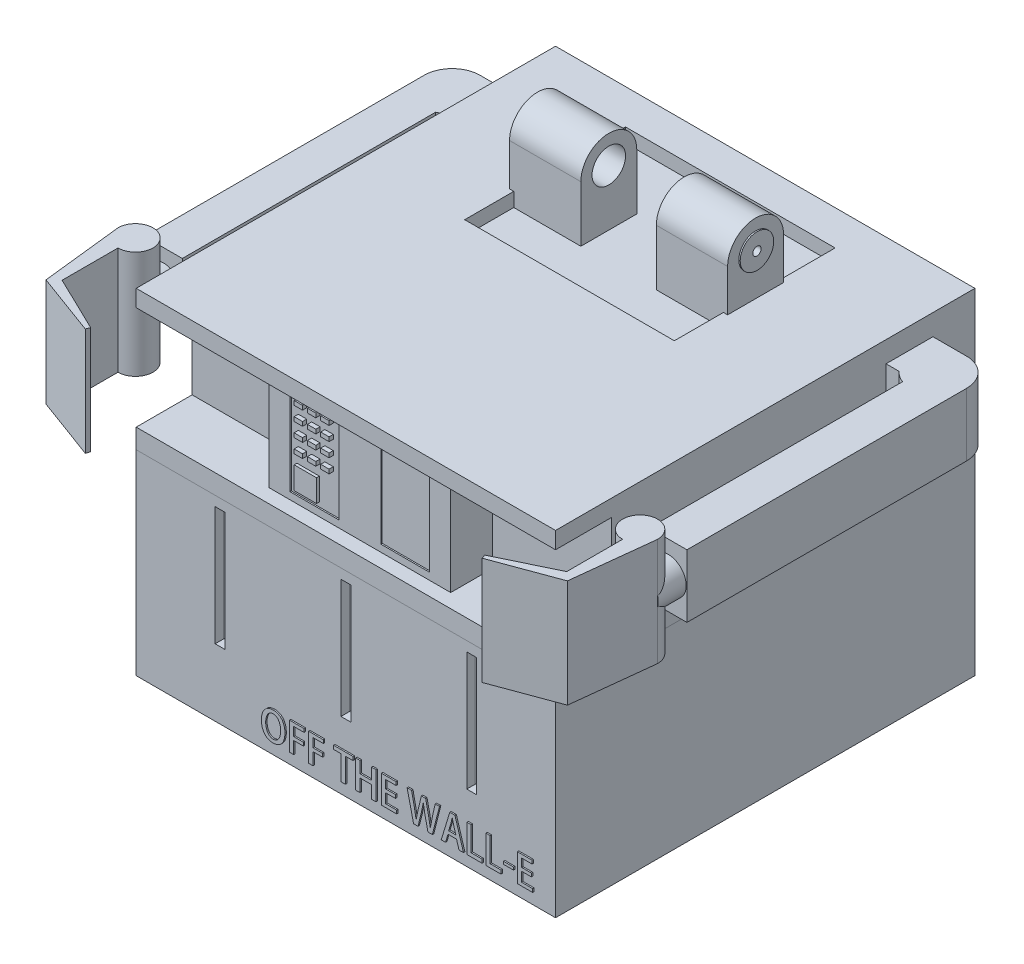
from build123d import *

# Parameters (mm, degrees)
BASE_W                                = 15
BASE_H                                = 15
BOTTOM_BASE_DEPTH                     = 7
BASE2_W                               = 15
BASE2_H                               = 15
TOP_BASE_DEPTH                        = 5
SKETCH3_W                             = 15
SKETCH3_H                             = 3.7
TOP_CUT_DEPTH                         = 2
SKETCH4_W                             = 6.5
SKETCH4_H                             = 3.7
BIG_BUTTON_PLATE_DEPTH                = 1.5
SKETCH6_W                             = 0.3
SKETCH6_H                             = 0.15
F_3X4_BUTTONS_DEPTH                   = 0.1
SKETCH9_W                             = 0.8
SKETCH9_H                             = 0.8
BIG_SQUARE_BUTTON_DEPTH               = 0.1
SKETCH6_6_W                           = 1.75
SKETCH6_6_H                           = 3.2
SKETCH6_6_W_2                         = 0.3
SKETCH6_6_H_2                         = 0.15
PHONE_DEPTH                           = 0.05
SKETCH14_W                            = 0.35
SKETCH14_H                            = 4.25
F_3_BOTTOM_SLOTS_DEPTH                = 0.35
FILLET1_R                             = 0.05
SKETCH15_W                            = 7.5
SKETCH15_H                            = 5.75
TOP_EXTRUDE_CUT_DEPTH                 = 0.5
RIGHT_HEAD_HOLDER_1_DEPTH             = 2.4
RIGHT_HEAD_HOLDER_1_DEPTH_BACK        = 0.15
SKETCH19_R                            = 0.6
RIGHT_HEAD_HOLDER_2_DEPTH             = 0.35
RIGHT_HEAD_HOLDER_2_DEPTH_BACK        = 0.2
SKETCH19_3_R                          = 0.6
SKETCH19_3_R_2                        = 0.15
LEFT_HEAD_HOLDER_1_DEPTH              = 2.4
LEFT_HEAD_HOLDER_1_DEPTH_BACK         = 0.15
SKETCH18_R                            = 0.6
LEFT_HEAD_HOLDER_2_DEPTH              = 0.35
LEFT_HEAD_HOLDER_2_DEPTH_BACK         = 0.2
SKETCH18_3_R                          = 0.6
SKETCH18_3_R_2                        = 0.15
ARMS_DEPTH                            = 2.25
CLAWS_DEPTH                           = 0.8
CLAWS_DEPTH_BACK                      = 3.05
CLAWS_2_DEPTH                         = 0.8
CLAWS_2_DEPTH_BACK                    = 3.05
SKETCH26_R                            = 0.65
CIRCLE_TO_ATTACH_ARMS_AND_CLAWS_DEPTH = 1
SKETCH28_W                            = 0.359189424
SKETCH28_H                            = 0.095238297
BOSS_EXTRUDE26_DEPTH                  = 0.05
SKETCH33_W                            = 1.5
SKETCH33_H                            = 1.5
CUT_EXTRUDE1_DEPTH                    = 2.5


with BuildPart() as part:
    # Base → Bottom base (new body)
    with BuildSketch(Plane(origin=(0, 0, 0), x_dir=(1, 0, 0), z_dir=(0, 1, 0))):
        Rectangle(BASE_W, BASE_H)
    extrude(amount=BOTTOM_BASE_DEPTH)

    # Sketch14 → 3 bottom slots (cut)
    with BuildSketch(Plane.XY.offset(7.5)):
        with Locations((0, 4.525)):
            Rectangle(SKETCH14_W, SKETCH14_H)
        with Locations((4.5, 4.525)):
            Rectangle(SKETCH14_W, SKETCH14_H)
        with Locations((-4.5, 4.525)):
            Rectangle(SKETCH14_W, SKETCH14_H)
    extrude(amount=-F_3_BOTTOM_SLOTS_DEPTH, mode=Mode.SUBTRACT)

    # Fillet1
    fillet1_edges = [part.edges().sort_by_distance(p)[0] for p in [
        (-0.175, 4.525, 7.15),
        (-4.675, 4.525, 7.15),
        (4.675, 4.525, 7.15),
        (4.5, 6.65, 7.15),
        (0.175, 4.525, 7.15),
        (0, 6.65, 7.15),
        (4.325, 4.525, 7.15),
        (4.5, 2.4, 7.15),
        (0, 2.4, 7.15),
        (-4.5, 2.4, 7.15),
        (-4.5, 6.65, 7.15),
        (-4.325, 4.525, 7.15),
    ]]
    fillet(fillet1_edges, radius=FILLET1_R)

    # Sketch28 → Boss-Extrude26 (add)
    # profile 1 of 12: a face of its own
    with BuildSketch(Plane.XY.offset(7.5)):
        with BuildLine():
            add(Edge.make_bspline(
                [(-2.542773415, 1.438775136), (-2.55882584, 1.438110923), (-2.59017136, 1.436813916), (-2.635834672, 1.429654226), (-2.678976734, 1.41865114), (-2.719463386, 1.403035452), (-2.757423202, 1.38326681), (-2.792716073, 1.359116703), (-2.825399223, 1.330752787), (-2.855279169, 1.298345473), (-2.882055278, 1.262197262), (-2.905669966, 1.222690536), (-2.925377124, 1.17977718), (-2.941932195, 1.133846801), (-2.954655386, 1.08466898), (-2.964079137, 1.032377645), (-2.969951963, 0.976854424), (-2.97105014, 0.938758011), (-2.971613422, 0.919217401)],
                knots=[0, 0, 0, 0, 1.01693825, 1.985772131, 2.921518734, 3.832117633, 4.727948323, 5.626511184, 6.534414133, 7.463288783, 8.412839634, 9.378967074, 10.373196777, 11.399194858, 12.46754142, 13.586614818, 14.762113956, 16, 16, 16, 16], degree=3))
            add(Edge.make_bspline(
                [(-2.971613422, 0.919217401), (-2.971208289, 0.900429172), (-2.970416523, 0.863710668), (-2.964426968, 0.810220053), (-2.956119813, 0.759588063), (-2.943575482, 0.712087769), (-2.928381776, 0.667333139), (-2.909052276, 0.625858504), (-2.886964026, 0.587076746), (-2.8612577, 0.55170149), (-2.832800775, 0.519545639), (-2.801228268, 0.491619405), (-2.766992422, 0.46781399), (-2.730017847, 0.448191723), (-2.690284694, 0.432873966), (-2.647883002, 0.421784598), (-2.602861971, 0.414647273), (-2.571917352, 0.413420404), (-2.556080466, 0.412792516)],
                knots=[0, 0, 0, 0, 1.222557966, 2.38928844, 3.500048728, 4.559063003, 5.583344684, 6.572073494, 7.532658458, 8.483942143, 9.413076429, 10.322121769, 11.220566177, 12.121066096, 13.040014193, 13.985715855, 14.969126498, 16, 16, 16, 16], degree=3))
            add(Edge.make_bspline(
                [(-2.556080466, 0.412792516), (-2.54075349, 0.413188806), (-2.510669922, 0.41396664), (-2.466682885, 0.420165519), (-2.424842983, 0.430077083), (-2.38526705, 0.444305975), (-2.348009795, 0.462822842), (-2.312864376, 0.485189664), (-2.279982063, 0.511738917), (-2.249253561, 0.542102642), (-2.221648907, 0.576876857), (-2.197202941, 0.615672953), (-2.176945288, 0.65894639), (-2.159942527, 0.706133976), (-2.146555767, 0.757497133), (-2.136920145, 0.812927523), (-2.130587189, 0.872528944), (-2.12942961, 0.913657954), (-2.12883171, 0.934901455)],
                knots=[0, 0, 0, 0, 0.964759122, 1.89361537, 2.791129421, 3.668077106, 4.535429534, 5.405715028, 6.285894481, 7.191747456, 8.120239528, 9.075412678, 10.072429751, 11.12252868, 12.229792465, 13.410030886, 14.662257747, 16, 16, 16, 16], degree=3))
            add(Edge.make_bspline(
                [(-2.12883171, 0.934901455), (-2.129145052, 0.95299104), (-2.12975776, 0.988363246), (-2.134927432, 1.040094869), (-2.143460291, 1.089133126), (-2.154882139, 1.135699503), (-2.169797366, 1.179671389), (-2.188169567, 1.221026594), (-2.209857994, 1.259758826), (-2.234383469, 1.295895008), (-2.262423291, 1.328524563), (-2.293489849, 1.357214635), (-2.327622631, 1.381751634), (-2.365000455, 1.401492806), (-2.405152647, 1.417631026), (-2.44846881, 1.428920554), (-2.494667177, 1.436482788), (-2.526508763, 1.437935279), (-2.542773415, 1.438775136)],
                knots=[0, 0, 0, 0, 1.181997023, 2.311265979, 3.393394717, 4.432710499, 5.441572568, 6.423779709, 7.385757606, 8.339154063, 9.273212536, 10.190881701, 11.096730823, 12.012033381, 12.946898792, 13.918455472, 14.931549697, 16, 16, 16, 16], degree=3))
        make_face()
        with BuildLine():
            add(Edge.make_bspline(
                [(-2.548066636, 1.31991609), (-2.537165417, 1.318983992), (-2.515855441, 1.317161903), (-2.484981242, 1.31054518), (-2.456310213, 1.300351113), (-2.429814447, 1.286594966), (-2.405742403, 1.269172675), (-2.383543332, 1.248629521), (-2.363840451, 1.224383101), (-2.346717009, 1.196948695), (-2.331589955, 1.167451879), (-2.318430785, 1.13658356), (-2.306908464, 1.104796692), (-2.29799648, 1.071757069), (-2.290669647, 1.037788882), (-2.285934581, 1.002655396), (-2.282735348, 0.966518333), (-2.282427136, 0.942026369), (-2.282270891, 0.929610449)],
                knots=[0, 0, 0, 0, 0.999589655, 1.954022852, 2.877517249, 3.773878129, 4.673599429, 5.586311784, 6.531597741, 7.520501744, 8.537853166, 9.559417173, 10.586727125, 11.626167667, 12.685579831, 13.761408337, 14.865171654, 16, 16, 16, 16], degree=3))
            add(Edge.make_bspline(
                [(-2.282270891, 0.929610449), (-2.282515675, 0.916063238), (-2.282995612, 0.889501882), (-2.28596674, 0.850426095), (-2.29128527, 0.813015414), (-2.298562117, 0.777117744), (-2.308300047, 0.742958305), (-2.31968806, 0.710261892), (-2.333651813, 0.679388185), (-2.349250923, 0.650198013), (-2.36712996, 0.623475447), (-2.387135503, 0.599901927), (-2.409359173, 0.579747293), (-2.433601588, 0.563029952), (-2.460016367, 0.549834402), (-2.488459567, 0.540284041), (-2.518878394, 0.533600178), (-2.539982794, 0.532311215), (-2.550789459, 0.531651192)],
                knots=[0, 0, 0, 0, 1.215141369, 2.382468418, 3.512223075, 4.602497428, 5.664896563, 6.695933009, 7.704955915, 8.700973005, 9.661508233, 10.583141316, 11.467103885, 12.344670232, 13.216342825, 14.106081872, 15.030205112, 16, 16, 16, 16], degree=3))
            add(Edge.make_bspline(
                [(-2.550789459, 0.531651192), (-2.561404923, 0.532397393), (-2.582186513, 0.53385821), (-2.612268391, 0.540448671), (-2.640452786, 0.550215414), (-2.666522509, 0.563599601), (-2.690700767, 0.580196186), (-2.712602066, 0.600478458), (-2.732893267, 0.623866029), (-2.750494325, 0.650723065), (-2.766275355, 0.679738522), (-2.7800325, 0.710402286), (-2.791879883, 0.742433556), (-2.80114964, 0.77598823), (-2.808854497, 0.810774186), (-2.814005122, 0.846973579), (-2.817330483, 0.884511626), (-2.817764383, 0.910013807), (-2.817985276, 0.922996691)],
                knots=[0, 0, 0, 0, 0.968573833, 1.896149455, 2.796477749, 3.679461465, 4.558257033, 5.460120664, 6.392036362, 7.372592241, 8.379386201, 9.399199485, 10.432362265, 11.48798156, 12.568687675, 13.676620176, 14.817192429, 16, 16, 16, 16], degree=3))
            add(Edge.make_bspline(
                [(-2.817985276, 0.922996691), (-2.817906472, 0.93566455), (-2.817750586, 0.960723784), (-2.814512109, 0.997678677), (-2.809767876, 1.033623912), (-2.802495327, 1.068302048), (-2.793463414, 1.101907221), (-2.782305831, 1.13439706), (-2.768830302, 1.165645515), (-2.753760089, 1.19566964), (-2.736462485, 1.223413999), (-2.716446665, 1.247918927), (-2.69405673, 1.268812858), (-2.669357094, 1.286293929), (-2.642284347, 1.300124753), (-2.612952929, 1.310551542), (-2.58132124, 1.317484158), (-2.559390721, 1.319029602), (-2.548066636, 1.31991609)],
                knots=[0, 0, 0, 0, 1.136547726, 2.248289582, 3.326834991, 4.389002452, 5.425786828, 6.448433384, 7.469124786, 8.477926495, 9.461316408, 10.397265518, 11.309260955, 12.201738065, 13.104381261, 14.028854752, 14.989125284, 16, 16, 16, 16], degree=3))
        make_face(mode=Mode.SUBTRACT)
    # profile 2 of 12: a face of its own
    with BuildSketch(Plane.XY.offset(7.5)):
        Polygon((-1.814205801, 0.421490419), (-1.814205801, 0.860354587), (-1.471996241, 0.860354587), (-1.471996241, 0.979213633), (-1.814205801, 0.979213633), (-1.814205801, 1.295728633), (-1.445873374, 1.295728633), (-1.445873374, 1.414587678), (-1.967645167, 1.414587678), (-1.967645167, 0.421490419), align=None)
    # profile 3 of 12: a face of its own
    with BuildSketch(Plane.XY.offset(7.5)):
        Polygon((-1.12486327, 0.421490419), (-1.12486327, 0.860354587), (-0.782653711, 0.860354587), (-0.782653711, 0.979213633), (-1.12486327, 0.979213633), (-1.12486327, 1.295728633), (-0.756530843, 1.295728633), (-0.756530843, 1.414587678), (-1.278302637, 1.414587678), (-1.278302637, 0.421490419), align=None)
    # profile 4 of 12: a face of its own
    with BuildSketch(Plane.XY.offset(7.5)):
        Polygon((0.306506351, 1.425859116), (-0.386370222, 1.425859116), (-0.386370222, 1.296550924), (-0.11730469, 1.296550924), (-0.11730469, 0.426659447), (0.036134676, 0.426659447), (0.036134676, 1.296550924), (0.306506351, 1.296550924), align=None)
    # profile 5 of 12: a face of its own
    with BuildSketch(Plane.XY.offset(7.5)):
        Polygon((1.124570067, 1.428519382), (0.971130701, 1.428519382), (0.971130701, 1.015778081), (0.556165007, 1.015778081), (0.556165007, 1.428519382), (0.40272564, 1.428519382), (0.40272564, 0.429720894), (0.556165007, 0.429720894), (0.556165007, 0.884258782), (0.971130701, 0.884258782), (0.971130701, 0.429720894), (1.124570067, 0.429720894), align=None)
    # profile 6 of 12: a face of its own
    with BuildSketch(Plane.XY.offset(7.5)):
        Polygon((1.868437532, 0.543839587), (1.475288381, 0.543839587), (1.475288381, 0.884542045), (1.825334801, 0.884542045), (1.825334801, 1.00340109), (1.475288381, 1.00340109), (1.475288381, 1.295728633), (1.846233095, 1.295728633), (1.846233095, 1.414587678), (1.321849015, 1.414587678), (1.321849015, 0.424980542), (1.868437532, 0.424980542), align=None)
    # profile 7 of 12: a face of its own
    with BuildSketch(Plane.XY.offset(7.5)):
        with BuildLine():
            Line((3.245765887, 1.425831067), (3.139055562, 0.953960298))
            add(Edge.make_bspline(
                [(3.139055562, 0.953960298), (3.132663135, 0.924375836), (3.119998725, 0.865764336), (3.1020337, 0.778168135), (3.085930576, 0.690954756), (3.07705063, 0.63264649), (3.07260538, 0.603457706)],
                knots=[0, 0, 0, 0, 1.01788206, 2.01658543, 3.007114032, 4, 4, 4, 4], degree=3))
            Line((3.07260538, 0.603457706), (3.068782909, 0.603457706))
            add(Edge.make_bspline(
                [(3.068782909, 0.603457706), (3.064621305, 0.632259681), (3.056258443, 0.690138076), (3.041702599, 0.777037426), (3.025081799, 0.864413942), (3.012568145, 0.922642729), (3.006278837, 0.951908261)],
                knots=[0, 0, 0, 0, 0.986163973, 1.981724799, 2.985623747, 4, 4, 4, 4], degree=3))
            Line((3.006278837, 0.951908261), (2.902210694, 1.426964854))
            Line((2.902210694, 1.426964854), (2.751254624, 1.426964854))
            Line((2.751254624, 1.426964854), (2.638037571, 0.954592148))
            add(Edge.make_bspline(
                [(2.638037571, 0.954592148), (2.630872403, 0.923406884), (2.61681508, 0.862224604), (2.596699251, 0.772299255), (2.578665214, 0.686135246), (2.569505115, 0.629634853), (2.565046708, 0.602134954)],
                knots=[0, 0, 0, 0, 1.066520868, 2.092404214, 3.071534041, 4, 4, 4, 4], degree=3))
            Line((2.565046708, 0.602134954), (2.562559536, 0.602140121))
            add(Edge.make_bspline(
                [(2.562559536, 0.602140121), (2.560300099, 0.615428557), (2.55570602, 0.642447728), (2.54874011, 0.683653591), (2.541417455, 0.726190662), (2.530665073, 0.785077644), (2.516739752, 0.860534551), (2.504767173, 0.921245095), (2.498720165, 0.951908261)],
                knots=[0, 0, 0, 0, 0.682369738, 1.387451828, 2.115611866, 2.867419731, 4.417822979, 6, 6, 6, 6], degree=3))
            Line((2.498720165, 0.951908261), (2.399891357, 1.426964854))
            Line((2.399891357, 1.426964854), (2.239838602, 1.426964854))
            Line((2.239838602, 1.426964854), (2.472766701, 0.425831067))
            Line((2.472766701, 0.425831067), (2.631530844, 0.425831067))
            Line((2.631530844, 0.425831067), (2.749953278, 0.910045241))
            add(Edge.make_bspline(
                [(2.749953278, 0.910045241), (2.753617344, 0.924555813), (2.760831191, 0.953124366), (2.770726599, 0.995475919), (2.780283244, 1.03650652), (2.791843212, 1.089662653), (2.80499902, 1.155496718), (2.813336322, 1.208364765), (2.817503292, 1.234788132)],
                knots=[0, 0, 0, 0, 0.811805786, 1.598290927, 2.359154387, 3.097023541, 4.549096894, 6, 6, 6, 6], degree=3))
            Line((2.817503292, 1.234788132), (2.821527277, 1.234976727))
            add(Edge.make_bspline(
                [(2.821527277, 1.234976727), (2.82469568, 1.208365765), (2.831034187, 1.155129548), (2.844522693, 1.075106184), (2.860318642, 0.993345399), (2.872490004, 0.938213226), (2.878727794, 0.90995814)],
                knots=[0, 0, 0, 0, 0.973823886, 1.948170723, 2.948443182, 4, 4, 4, 4], degree=3))
            Line((2.878727794, 0.90995814), (2.986798147, 0.425831067))
            Line((2.986798147, 0.425831067), (3.144260944, 0.425831067))
            Line((3.144260944, 0.425831067), (3.399324648, 1.426964854))
            Line((3.399324648, 1.426964854), (3.245765887, 1.425831067))
        make_face()
    # profile 8 of 12: a face of its own
    with BuildSketch(Plane.XY.offset(7.5)):
        Polygon((3.9523852, 1.426512188), (3.766939047, 1.426512188), (3.461305192, 0.421347588), (3.616753782, 0.421347588), (3.702947065, 0.715229844), (4.008541429, 0.715229844), (4.098652588, 0.421347588), (4.257979564, 0.421347588), align=None)
        with BuildLine():
            Line((3.726454323, 0.83408889), (3.806117812, 1.098552471))
            add(Edge.make_bspline(
                [(3.806117812, 1.098552471), (3.810378493, 1.114590054), (3.819076241, 1.147329146), (3.83055211, 1.197153881), (3.841903727, 1.246876142), (3.849377993, 1.279761021), (3.853028805, 1.295823669)],
                knots=[0, 0, 0, 0, 0.981880665, 2.004409445, 3.025252049, 4, 4, 4, 4], degree=3))
            Line((3.853028805, 1.295823669), (3.855744247, 1.295897852))
            add(Edge.make_bspline(
                [(3.855744247, 1.295897852), (3.859406222, 1.279929837), (3.866906617, 1.247224421), (3.878892873, 1.19768297), (3.891585867, 1.147389791), (3.900662415, 1.113901091), (3.905183009, 1.097221969)],
                knots=[0, 0, 0, 0, 0.960134074, 1.966530216, 2.987225846, 4, 4, 4, 4], degree=3))
            Line((3.905183009, 1.097221969), (3.983728212, 0.83408889))
            Line((3.983728212, 0.83408889), (3.726454323, 0.83408889))
        make_face(mode=Mode.SUBTRACT)
    # profile 9 of 12: a face of its own
    with BuildSketch(Plane.XY.offset(7.5)):
        Polygon((4.92031401, 0.555082791), (4.53500172, 0.555082791), (4.53500172, 1.426280411), (4.381562353, 1.426280411), (4.381562353, 0.425831067), (4.92031401, 0.425831067), align=None)
    # profile 10 of 12: a face of its own
    with BuildSketch(Plane.XY.offset(7.5)):
        Polygon((5.597562813, 0.555082791), (5.212250522, 0.555082791), (5.212250522, 1.426280411), (5.058811156, 1.426280411), (5.058811156, 0.425831067), (5.597562813, 0.425831067), align=None)
    # profile 11 of 12: a face of its own
    with BuildSketch(Plane.XY.offset(7.5)):
        with Locations((5.867201512, 0.823034374)):
            Rectangle(SKETCH28_W, SKETCH28_H)
    # profile 12 of 12: a face of its own
    with BuildSketch(Plane.XY.offset(7.5)):
        Polygon((6.730116434, 0.543839587), (6.336967283, 0.543839587), (6.336967283, 0.884542045), (6.687013703, 0.884542045), (6.687013703, 1.00340109), (6.336967283, 1.00340109), (6.336967283, 1.295728633), (6.707911996, 1.295728633), (6.707911996, 1.414587678), (6.183527917, 1.414587678), (6.183527917, 0.424980542), (6.730116434, 0.424980542), align=None)
    extrude(amount=BOSS_EXTRUDE26_DEPTH)

    # Sketch33 → Cut-Extrude1 (cut)
    with BuildSketch(Plane.XZ):
        with Locations((-6, 0.5)):
            Rectangle(SKETCH33_W, SKETCH33_H)
        with Locations((6, 0.5)):
            Rectangle(SKETCH33_W, SKETCH33_H)
    extrude(amount=-CUT_EXTRUDE1_DEPTH, mode=Mode.SUBTRACT)


with BuildPart() as body_2:
    # Base2 → Top base (new body)
    with BuildSketch(Plane(origin=(0, 7, 0), x_dir=(1, 0, 0), z_dir=(0, 1, 0))):
        Rectangle(BASE2_W, BASE2_H)
    extrude(amount=TOP_BASE_DEPTH)

    # Sketch3 → Top cut (cut)
    with BuildSketch(Plane.XY.offset(7.5)):
        with Locations((0, 9.55)):
            Rectangle(SKETCH3_W, SKETCH3_H)
    extrude(amount=-TOP_CUT_DEPTH, mode=Mode.SUBTRACT)

    # Sketch4 → Big button plate (add)
    with BuildSketch(Plane.XY.offset(5.5)):
        with Locations((0, 9.55)):
            Rectangle(SKETCH4_W, SKETCH4_H)
    extrude(amount=BIG_BUTTON_PLATE_DEPTH)

    # Sketch6 → 3x4 buttons (add)
    with BuildSketch(Plane.XY.offset(7)):
        with Locations((-1.625, 10.874059361)):
            Rectangle(SKETCH6_W, SKETCH6_H)
        with Locations((-2.1, 10.874059361)):
            Rectangle(SKETCH6_W, SKETCH6_H)
        with Locations((-1.15, 10.874059361)):
            Rectangle(SKETCH6_W, SKETCH6_H)
        with Locations((-2.1, 10.374059361)):
            Rectangle(SKETCH6_W, SKETCH6_H)
        with Locations((-1.625, 10.374059361)):
            Rectangle(SKETCH6_W, SKETCH6_H)
        with Locations((-1.15, 10.374059361)):
            Rectangle(SKETCH6_W, SKETCH6_H)
        with Locations((-2.1, 9.874059361)):
            Rectangle(SKETCH6_W, SKETCH6_H)
        with Locations((-1.625, 9.874059361)):
            Rectangle(SKETCH6_W, SKETCH6_H)
        with Locations((-1.15, 9.874059361)):
            Rectangle(SKETCH6_W, SKETCH6_H)
        with Locations((-2.1, 9.374059361)):
            Rectangle(SKETCH6_W, SKETCH6_H)
        with Locations((-1.625, 9.374059361)):
            Rectangle(SKETCH6_W, SKETCH6_H)
        with Locations((-1.15, 9.374059361)):
            Rectangle(SKETCH6_W, SKETCH6_H)
    extrude(amount=F_3X4_BUTTONS_DEPTH)

    # Sketch9 → Big square button (add)
    with BuildSketch(Plane.XY.offset(7)):
        with Locations((-1.85, 8.55732297)):
            Rectangle(SKETCH9_W, SKETCH9_H)
    extrude(amount=BIG_SQUARE_BUTTON_DEPTH)

    # Sketch6_6 → phone (cut)
    # profile 1 of 2: a face of its own
    with BuildSketch(Plane.XY.offset(7)):
        with Locations((-1.625, 9.55)):
            Rectangle(SKETCH6_6_W, SKETCH6_6_H)
        with Locations((-1.625, 10.874059361)):
            Rectangle(SKETCH6_6_W_2, SKETCH6_6_H_2, mode=Mode.SUBTRACT)
        with Locations((-2.1, 10.874059361)):
            Rectangle(SKETCH6_6_W_2, SKETCH6_6_H_2, mode=Mode.SUBTRACT)
        with Locations((-1.15, 10.874059361)):
            Rectangle(SKETCH6_6_W_2, SKETCH6_6_H_2, mode=Mode.SUBTRACT)
        with Locations((-2.1, 10.374059361)):
            Rectangle(SKETCH6_6_W_2, SKETCH6_6_H_2, mode=Mode.SUBTRACT)
        with Locations((-1.625, 10.374059361)):
            Rectangle(SKETCH6_6_W_2, SKETCH6_6_H_2, mode=Mode.SUBTRACT)
        with Locations((-1.15, 10.374059361)):
            Rectangle(SKETCH6_6_W_2, SKETCH6_6_H_2, mode=Mode.SUBTRACT)
        with Locations((-2.1, 9.874059361)):
            Rectangle(SKETCH6_6_W_2, SKETCH6_6_H_2, mode=Mode.SUBTRACT)
        with Locations((-1.625, 9.874059361)):
            Rectangle(SKETCH6_6_W_2, SKETCH6_6_H_2, mode=Mode.SUBTRACT)
        with Locations((-1.15, 9.874059361)):
            Rectangle(SKETCH6_6_W_2, SKETCH6_6_H_2, mode=Mode.SUBTRACT)
        with Locations((-2.1, 9.374059361)):
            Rectangle(SKETCH6_6_W_2, SKETCH6_6_H_2, mode=Mode.SUBTRACT)
        with Locations((-1.625, 9.374059361)):
            Rectangle(SKETCH6_6_W_2, SKETCH6_6_H_2, mode=Mode.SUBTRACT)
        with Locations((-1.15, 9.374059361)):
            Rectangle(SKETCH6_6_W_2, SKETCH6_6_H_2, mode=Mode.SUBTRACT)
    # profile 2 of 2: a face of its own
    with BuildSketch(Plane.XY.offset(7)):
        with Locations((1.625, 9.55)):
            Rectangle(SKETCH6_6_W, SKETCH6_6_H)
    extrude(amount=-PHONE_DEPTH, mode=Mode.SUBTRACT)


with BuildPart() as phone_piece_1:
    # of the separate pieces the step leaves, piece 1, a body of its own (phone_pieces)
    add(body_2.part.solids().sort_by_distance((-7.5, 7, 7.5))[0])

    # Sketch15 → Top extrude cut (cut)
    with BuildSketch(Plane(origin=(0, 12, 0), x_dir=(1, 0, 0), z_dir=(0, 1, 0))):
        with Locations((0, 3.375)):
            Rectangle(SKETCH15_W, SKETCH15_H)
    extrude(amount=-TOP_EXTRUDE_CUT_DEPTH, mode=Mode.SUBTRACT)

    # Sketch19 → Right head holder 1 (add, two sides: drawn at the far end of the back side and taken through both)
    with BuildSketch(Plane.ZY.offset(-3.75).offset(-RIGHT_HEAD_HOLDER_1_DEPTH_BACK)):
        with BuildLine():
            ThreePointArc((-2.255590817, 13.5), (-3.255590817, 14.5), (-4.255590817, 13.5))
            Line((-4.255590817, 13.5), (-4.255590817, 11.5))
            Line((-4.255590817, 11.5), (-2.255590817, 11.5))
            Line((-2.255590817, 11.5), (-2.255590817, 13.5))
        make_face()
        with Locations((-3.255590817, 13.5)):
            Circle(SKETCH19_R, mode=Mode.SUBTRACT)
    extrude(amount=RIGHT_HEAD_HOLDER_1_DEPTH + RIGHT_HEAD_HOLDER_1_DEPTH_BACK)

    # Sketch19_3 → Right head holder 2 (add, two sides: drawn at the far end of the back side and taken through both)
    with BuildSketch(Plane.ZY.offset(-3.75).offset(-RIGHT_HEAD_HOLDER_2_DEPTH_BACK)):
        with Locations((-3.255590817, 13.5)):
            Circle(SKETCH19_3_R)
        with Locations((-3.255590817, 13.5)):
            Circle(SKETCH19_3_R_2, mode=Mode.SUBTRACT)
    extrude(amount=RIGHT_HEAD_HOLDER_2_DEPTH + RIGHT_HEAD_HOLDER_2_DEPTH_BACK)

    # Sketch18 → Left head holder 1 (add, two sides: drawn at the far end of the back side and taken through both)
    with BuildSketch(Plane(origin=(-3.75, 0, 0), x_dir=(0, 0, -1), z_dir=(1, 0, 0)).offset(-LEFT_HEAD_HOLDER_1_DEPTH_BACK)):
        with BuildLine():
            Line((2.255590817, 11.5), (4.255590817, 11.5))
            Line((4.255590817, 11.5), (4.255590817, 13.5))
            ThreePointArc((4.255590817, 13.5), (3.255590817, 14.5), (2.255590817, 13.5))
            Line((2.255590817, 13.5), (2.255590817, 11.5))
        make_face()
        with Locations((3.255590817, 13.5)):
            Circle(SKETCH18_R, mode=Mode.SUBTRACT)
    extrude(amount=LEFT_HEAD_HOLDER_1_DEPTH + LEFT_HEAD_HOLDER_1_DEPTH_BACK)

    # Sketch18_3 → Left head holder 2 (add, two sides: drawn at the far end of the back side and taken through both)
    with BuildSketch(Plane(origin=(-3.75, 0, 0), x_dir=(0, 0, -1), z_dir=(1, 0, 0)).offset(-LEFT_HEAD_HOLDER_2_DEPTH_BACK)):
        with Locations((3.255590817, 13.5)):
            Circle(SKETCH18_3_R)
        with Locations((3.255590817, 13.5)):
            Circle(SKETCH18_3_R_2, mode=Mode.SUBTRACT)
    extrude(amount=LEFT_HEAD_HOLDER_2_DEPTH + LEFT_HEAD_HOLDER_2_DEPTH_BACK)

    # Sketch21 → arms (add)
    with BuildSketch(Plane(origin=(0, 9, 0), x_dir=(1, 0, 0), z_dir=(0, 1, 0))):
        with BuildLine():
            Line((7.5, 4.322915521), (7.964094701, 4.322915521))
            ThreePointArc((7.964094701, 4.322915521), (8.141740127, 4.170333854), (8.35, 4.0632503))
            Line((8.35, 4.0632503), (8.35, -5))
            Line((8.35, -5), (9.7, -5))
            Line((9.7, -5), (9.7, 5))
            ThreePointArc((9.7, 5), (9.407106781, 5.707106781), (8.7, 6))
            Line((8.7, 6), (7.5, 6))
            Line((7.5, 6), (7.5, 4.322915521))
        make_face()
        with BuildLine():
            Line((-7.5, 6), (-8.7, 6))
            ThreePointArc((-8.7, 6), (-9.407106781, 5.707106781), (-9.7, 5))
            Line((-9.7, 5), (-9.7, -5))
            Line((-9.7, -5), (-8.35, -5))
            Line((-8.35, -5), (-8.35, 4.0632503))
            ThreePointArc((-8.35, 4.0632503), (-8.141740127, 4.170333854), (-7.964094701, 4.322915521))
            Line((-7.964094701, 4.322915521), (-7.5, 4.322915521))
            Line((-7.5, 4.322915521), (-7.5, 6))
        make_face()
    extrude(amount=ARMS_DEPTH)



with BuildPart() as phone_piece_2:
    # of the separate pieces the step leaves, piece 2, a body of its own (phone_pieces)
    add(body_2.part.solids().sort_by_distance((-2.25, 8.95732297, 7))[0])


with BuildPart() as body_4:
    # Sketch25 → claws (new, two sides: drawn at the far end of the back side and taken through both)
    with BuildSketch(Plane(origin=(0, 11.25, 0), x_dir=(1, 0, 0), z_dir=(0, 1, 0)).offset(-CLAWS_DEPTH_BACK)):
        with BuildLine():
            ThreePointArc((9.65, -6), (8.583058262, -5.558058262), (9.025, -6.625))
            Line((9.025, -6.625), (9.025, -8.625))
            Line((9.025, -8.625), (7.048208811, -9.580762133))
            Line((7.048208811, -9.580762133), (7.100145112, -9.721483918))
            Line((7.100145112, -9.721483918), (9.325961764, -8.9))
            Line((9.325961764, -8.9), (9.65, -6))
        make_face()
    extrude(amount=CLAWS_DEPTH + CLAWS_DEPTH_BACK)


with BuildPart() as body_5:
    # Sketch25 → claws 2 (new, two sides: drawn at the far end of the back side and taken through both)
    with BuildSketch(Plane(origin=(0, 11.25, 0), x_dir=(1, 0, 0), z_dir=(0, 1, 0)).offset(-CLAWS_2_DEPTH_BACK)):
        with BuildLine():
            Line((-9.325961764, -8.9), (-7.100145112, -9.721483918))
            Line((-7.100145112, -9.721483918), (-7.048208811, -9.580762133))
            Line((-7.048208811, -9.580762133), (-9.025, -8.625))
            Line((-9.025, -8.625), (-9.025, -6.625))
            ThreePointArc((-9.025, -6.625), (-8.583058262, -5.558058262), (-9.65, -6))
            Line((-9.65, -6), (-9.325961764, -8.9))
        make_face()
    extrude(amount=CLAWS_2_DEPTH + CLAWS_2_DEPTH_BACK)


with BuildPart() as phone_piece_1_1:
    add(phone_piece_1.part)

    add(body_4.part)  # circle to attach arms and claws merges body 4

    add(body_5.part)  # circle to attach arms and claws merges body 5
    # Sketch26 → circle to attach arms and claws (add)
    with BuildSketch(Plane.XY.offset(5)):
        with Locations((9.025, 10.125)):
            Circle(SKETCH26_R)
        with Locations((-9.025, 10.125)):
            Circle(SKETCH26_R)
    extrude(amount=CIRCLE_TO_ATTACH_ARMS_AND_CLAWS_DEPTH)


solid = Compound([part.part, phone_piece_2.part, phone_piece_1_1.part])
